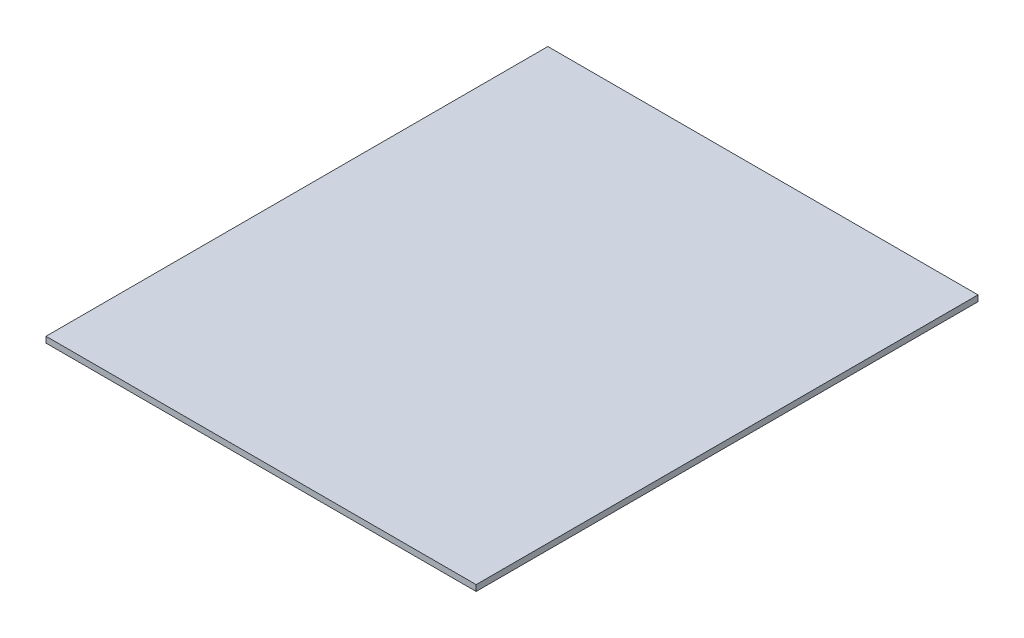
from build123d import *

# Parameters (mm, degrees)
SKETCH1_W           = 228.6
SKETCH1_H           = 266.7
BOSS_EXTRUDE1_DEPTH = 3.175


with BuildPart() as part:
    # Sketch1 → Boss-Extrude1 (new body)
    with BuildSketch(Plane(origin=(0, 0, 0), x_dir=(1, 0, 0), z_dir=(0, 1, 0))):
        Rectangle(SKETCH1_W, SKETCH1_H)
    extrude(amount=BOSS_EXTRUDE1_DEPTH)


solid = part.part
